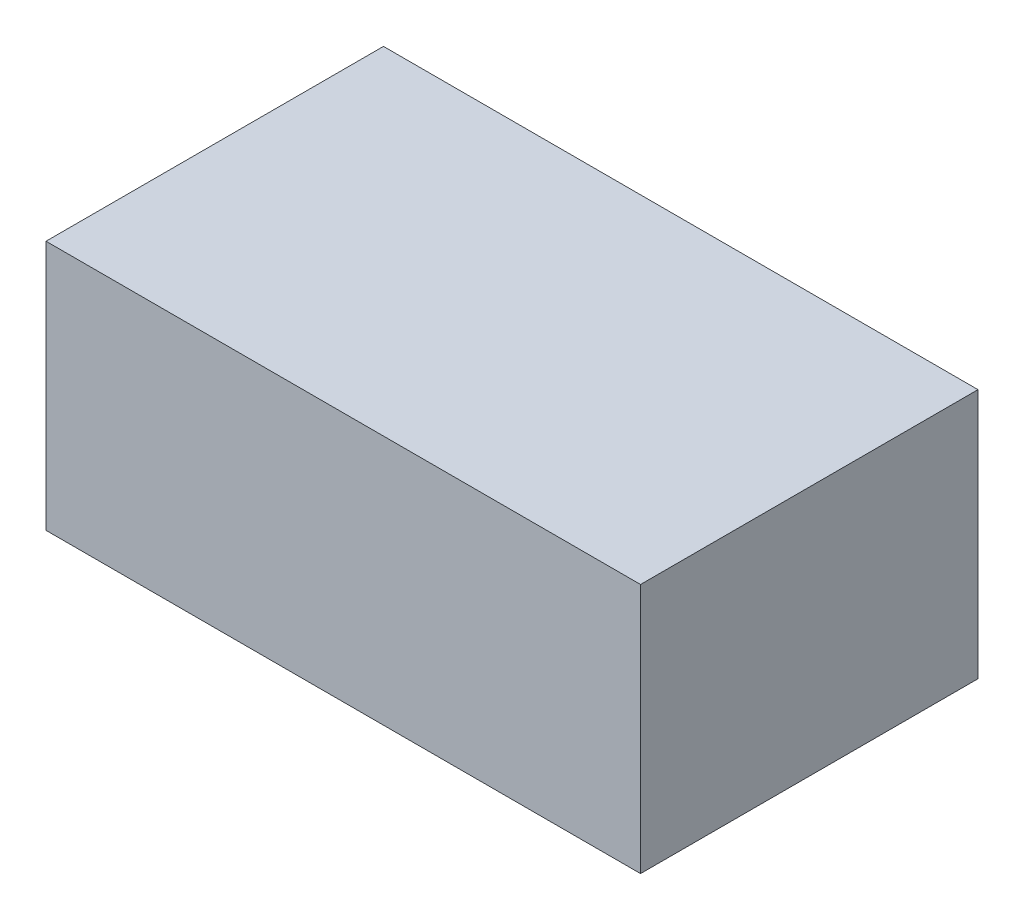
from build123d import *

# Parameters (mm, degrees)
SKETCH1_W           = 166.205133434
SKETCH1_H           = 94.34184828
BOSS_EXTRUDE1_DEPTH = 35


with BuildPart() as part:
    # Sketch1 → Boss-Extrude1 (new body, symmetric)
    with BuildSketch(Plane(origin=(0, 0, 0), x_dir=(1, 0, 0), z_dir=(0, 1, 0))):
        Rectangle(SKETCH1_W, SKETCH1_H)
    extrude(amount=BOSS_EXTRUDE1_DEPTH, both=True)


solid = part.part
